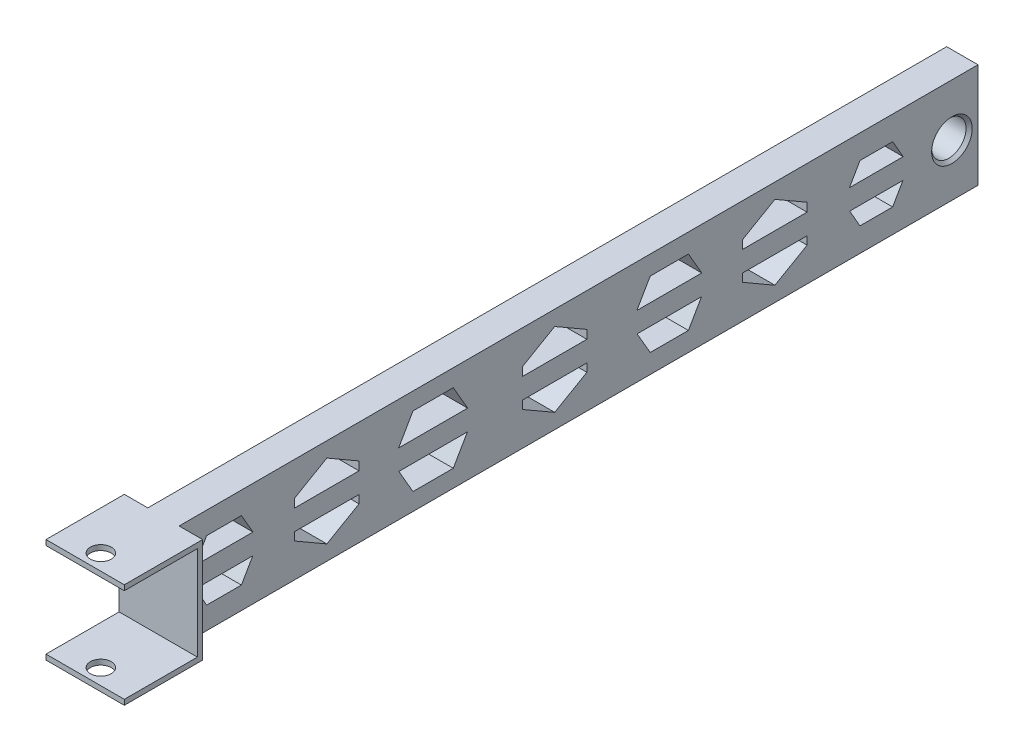
from build123d import *

# Parameters (mm, degrees)
SKETCH_1_W                      = 6
SKETCH_1_H                      = 20
EXTRUDE_1_DEPTH                 = 165
HOLE_WIZARD_G1_16_1_D           = 6.6
HOLE_WIZARD_G1_16_1_DEPTH       = 50
HOLE_WIZARD_G1_16_1_CSINK_D     = 7.773
HOLE_WIZARD_G1_16_1_CSINK_ANGLE = 90
HOLE_WIZARD_G1_16_1_TIP         = 1.982840043
SKETCH_5_W                      = 15
SKETCH_5_H                      = 20
EXTRUDE_2_DEPTH                 = 10
EXTRUDE_2_DEPTH_BACK            = 15
SKETCH_6_W                      = 5.5
SKETCH_6_H                      = 15
SKETCH_6_W_2                    = 4.5
CUT_EXTRUDE_1_DEPTH             = 32
SKETCH_7_W                      = 15
SKETCH_7_H                      = 18
CUT_EXTRUDE_2_DEPTH             = 14
SKETCH_8_R                      = 2
CUT_EXTRUDE_3_DEPTH             = 39
CUT_EXTRUDE_4_DEPTH             = 70


with BuildPart() as part:
    # 草图1 → 凸台-拉伸1 (new body)
    with BuildSketch(Plane.XY):
        Rectangle(SKETCH_1_W, SKETCH_1_H)
    extrude(amount=EXTRUDE_1_DEPTH)

    # G1/16 螺纹孔1
    with Locations(Plane(origin=(3, 0, 0), x_dir=(0, 0, -1), z_dir=(1, 0, 0))):
        with Locations((-5, 0)):
            CounterSinkHole(HOLE_WIZARD_G1_16_1_D / 2, HOLE_WIZARD_G1_16_1_CSINK_D / 2, depth=HOLE_WIZARD_G1_16_1_DEPTH, counter_sink_angle=HOLE_WIZARD_G1_16_1_CSINK_ANGLE)
            with Locations((0, 0, -(HOLE_WIZARD_G1_16_1_DEPTH + HOLE_WIZARD_G1_16_1_TIP / 2))):  # 118° drill point
                Cone(0, HOLE_WIZARD_G1_16_1_D / 2, HOLE_WIZARD_G1_16_1_TIP, mode=Mode.SUBTRACT)

    # 草图5 → 凸台-拉伸2 (add, two sides)
    with BuildSketch(Plane(origin=(3, 0, 0), x_dir=(0, 0, -1), z_dir=(1, 0, 0))) as extrude_2_sk:
        with Locations((-160.5, 0)):
            Rectangle(SKETCH_5_W, SKETCH_5_H)
    extrude(amount=EXTRUDE_2_DEPTH)
    extrude(extrude_2_sk.sketch, amount=-EXTRUDE_2_DEPTH_BACK)

    # 草图6 → 切除-拉伸1 (cut)
    with BuildSketch(Plane.XZ.offset(10)):
        with Locations((10.25, 160.5)):
            Rectangle(SKETCH_6_W, SKETCH_6_H)
        with Locations((-9.75, 160.5)):
            Rectangle(SKETCH_6_W_2, SKETCH_6_H)
    extrude(amount=-CUT_EXTRUDE_1_DEPTH, mode=Mode.SUBTRACT)

    # 草图7 → 切除-拉伸2 (cut)
    with BuildSketch(Plane.XY.offset(168)):
        Rectangle(SKETCH_7_W, SKETCH_7_H)
    extrude(amount=-CUT_EXTRUDE_2_DEPTH, mode=Mode.SUBTRACT)

    # 草图8 → 切除-拉伸3 (cut)
    with BuildSketch(Plane(origin=(0, 10, 0), x_dir=(1, 0, 0), z_dir=(0, 1, 0))):
        with Locations((0, -165)):
            Circle(SKETCH_8_R)
    extrude(amount=-CUT_EXTRUDE_3_DEPTH, mode=Mode.SUBTRACT)

    # 草图9 → 切除-拉伸4 (cut)
    with BuildSketch(Plane.ZY.offset(3)):
        Polygon((14.328441006, 1.918732887), (24.619003084, 1.918732887), (22.600253038, 5.415310533), (16.347191051, 5.415310533), align=None)
        Polygon((22.600253038, -5.415310533), (24.57465807, -1.995540703), (14.372786019, -1.995540703), (16.347191051, -5.415310533), align=None)
        Polygon((32.73389091, 1.918732887), (45.062363825, 1.918732887), (45.062363825, 3.558923578), (38.898127367, 7.117847156), (32.73389091, 3.558923578), align=None)
        Polygon((45.062363825, -3.558923578), (45.062363825, -1.995540703), (32.73389091, -1.995540703), (32.73389091, -3.558923578), (38.898127367, -7.117847156), align=None)
        Polygon((52.911163907, 1.918732887), (65.330427938, 1.918732887), (62.779502404, 6.337065517), (55.46208944, 6.337065517), align=None)
        Polygon((62.779502404, -6.337065517), (65.286082924, -1.995540703), (52.95550892, -1.995540703), (55.46208944, -6.337065517), align=None)
        Polygon((87.237271272, -3.558923578), (87.237271272, -1.995540703), (74.908798357, -1.995540703), (74.908798357, -3.558923578), (81.073034814, -7.117847156), align=None)
        Polygon((74.908798357, 1.918732887), (87.237271272, 1.918732887), (87.237271272, 3.558923578), (81.073034814, 7.117847156), (74.908798357, 3.558923578), align=None)
        Polygon((97.746948796, 1.918732887), (110.964476059, 1.918732887), (108.213984717, 6.682723636), (100.497440137, 6.682723636), align=None)
        Polygon((108.213984717, -6.682723636), (110.920131045, -1.995540703), (97.791293809, -1.995540703), (100.497440137, -6.682723636), align=None)
        Polygon((118.547188397, 1.918732887), (130.875661312, 1.918732887), (130.875661312, 3.558923578), (124.711424854, 7.117847156), (118.547188397, 3.558923578), align=None)
        Polygon((130.875661312, -3.558923578), (130.875661312, -1.995540703), (118.547188397, -1.995540703), (118.547188397, -3.558923578), (124.711424854, -7.117847156), align=None)
        Polygon((138.857505266, 1.918732887), (149.946330576, 1.918732887), (147.728014723, 5.760968652), (141.075821119, 5.760968652), align=None)
        Polygon((147.728014723, -5.760968652), (149.901985563, -1.995540703), (138.901850279, -1.995540703), (141.075821119, -5.760968652), align=None)
    extrude(amount=-CUT_EXTRUDE_4_DEPTH, mode=Mode.SUBTRACT)


solid = part.part
